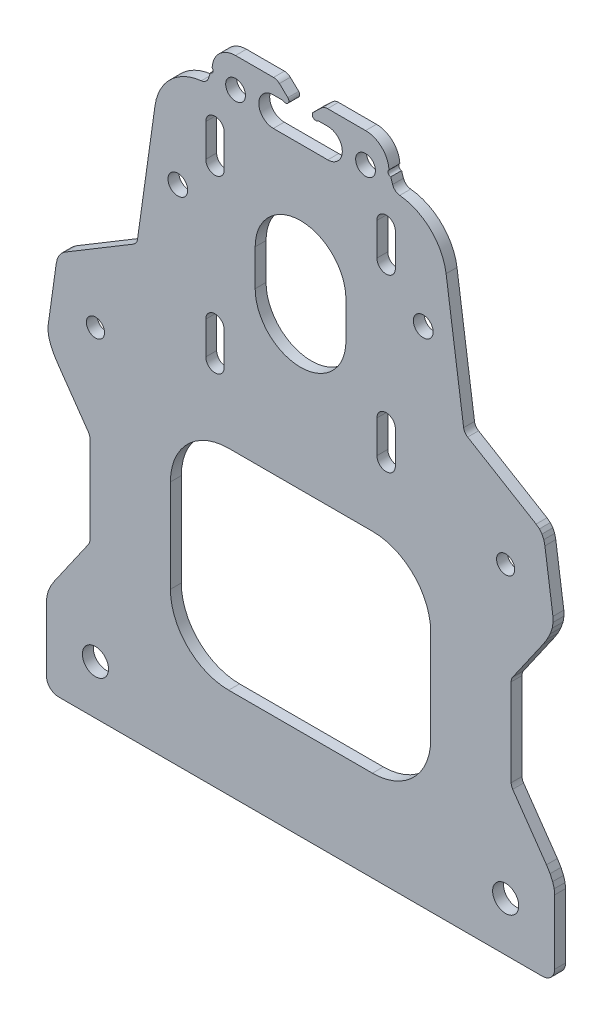
from build123d import *

# Parameters (mm, degrees)
MODEL_R             = 3.6
MODEL_R_2           = 2.725
MODEL_R_3           = 2.5
BOSS_EXTRUDE1_DEPTH = 3


with BuildPart() as part:
    # Model → Boss-Extrude1 (new body)
    with BuildSketch(Plane.XY):
        with BuildLine():
            Line((-66.64035, 0), (66.64035, 0))
            ThreePointArc((66.64035, 0), (69.016228785, 0.984121215), (70.00035, 3.36))
            Line((70.00035, 3.36), (70.00035, 21.1105))
            Line((70.00035, 21.1105), (69.86629813, 22.498114684))
            Line((69.86629813, 22.498114684), (69.446311232, 23.988387428))
            Line((69.446311232, 23.988387428), (68.733529412, 25.548929055))
            Line((68.733529412, 25.548929055), (67.734761359, 27.16155254))
            Line((67.734761359, 27.16155254), (58.431673409, 40.525169242))
            ThreePointArc((58.431673409, 40.525169242), (58.118153534, 41.164216889), (58.01035, 41.867818343))
            Line((58.01035, 41.867818343), (58.01035, 65.939651469))
            ThreePointArc((58.01035, 65.939651469), (58.11831888, 66.643779624), (58.432304432, 67.283206562))
            Line((58.432304432, 67.283206562), (66.78383855, 79.267931576))
            Line((66.78383855, 79.267931576), (67.914068691, 81.051661321))
            Line((67.914068691, 81.051661321), (68.763177176, 82.764680123))
            Line((68.763177176, 82.764680123), (69.316681884, 84.394671222))
            Line((69.316681884, 84.394671222), (69.565395366, 85.915970428))
            Line((69.565395366, 85.915970428), (69.519060346, 87.308284697))
            Line((69.519060346, 87.308284697), (67.30949192, 103.030180971))
            Line((67.30949192, 103.030180971), (66.999561947, 104.350057085))
            Line((66.999561947, 104.350057085), (66.487504991, 105.437863083))
            Line((66.487504991, 105.437863083), (65.782163484, 106.319853558))
            Line((65.782163484, 106.319853558), (64.875433482, 107.017560512))
            Line((64.875433482, 107.017560512), (46.0351373, 118.337952538))
            ThreePointArc((46.0351373, 118.337952538), (45.285845094, 119.055243779), (44.918346815, 120.025238907))
            Line((44.918346815, 120.025238907), (40.094015429, 154.352140382))
            ThreePointArc((40.094015429, 154.352140382), (35.836168672, 162.70125074), (27.337884769, 166.652968529))
            ThreePointArc((27.337884769, 166.652968529), (26.108825382, 167.158066229), (25.350203438, 168.24903067))
            Line((25.350203438, 168.24903067), (24.828755998, 169.817409171))
            ThreePointArc((24.828755998, 169.817409171), (24.117671094, 170.371357056), (24.355513409, 171.2408))
            ThreePointArc((24.355513409, 171.2408), (22.368316822, 175.612570409), (17.911140334, 177.4))
            Line((17.911140334, 177.4), (7.437786988, 177.4))
            ThreePointArc((7.437786988, 177.4), (6.567071518, 177.232740152), (5.820301357, 176.754769847))
            Line((5.820301357, 176.754769847), (3.50035, 174.5536))
            ThreePointArc((3.50035, 174.5536), (3.500375, 173.207275), (4.8467, 173.2073))
            Line((4.8467, 173.2073), (7.50035, 173.2073))
            ThreePointArc((7.50035, 173.2073), (11.50035, 169.2073), (7.50035, 165.2073))
            Line((7.50035, 165.2073), (-7.49965, 165.2073))
            ThreePointArc((-7.49965, 165.2073), (-11.49965, 169.2073), (-7.49965, 173.2073))
            Line((-7.49965, 173.2073), (-4.846, 173.2073))
            ThreePointArc((-4.846, 173.2073), (-3.499675, 173.207275), (-3.49965, 174.5536))
            Line((-3.49965, 174.5536), (-5.819601357, 176.754769848))
            ThreePointArc((-5.819601357, 176.754769848), (-6.566371518, 177.232740152), (-7.437086988, 177.4))
            Line((-7.437086988, 177.4), (-17.910440334, 177.4))
            ThreePointArc((-17.910440334, 177.4), (-22.367616822, 175.612570409), (-24.354813409, 171.2408))
            ThreePointArc((-24.354813409, 171.2408), (-24.116971094, 170.371357056), (-24.828055998, 169.817409171))
            Line((-24.828055998, 169.817409171), (-25.349503438, 168.24903067))
            ThreePointArc((-25.349503438, 168.24903067), (-26.108125382, 167.158066229), (-27.337184769, 166.652968529))
            ThreePointArc((-27.337184769, 166.652968529), (-35.835468672, 162.70125074), (-40.093315429, 154.352140382))
            Line((-40.093315429, 154.352140382), (-44.917646815, 120.025238907))
            ThreePointArc((-44.917646815, 120.025238907), (-45.285145095, 119.055243779), (-46.0344373, 118.337952538))
            Line((-46.0344373, 118.337952538), (-64.874733482, 107.017560512))
            Line((-64.874733482, 107.017560512), (-65.764454542, 106.336263813))
            Line((-65.764454542, 106.336263813), (-66.464064741, 105.473352073))
            Line((-66.464064741, 105.473352073), (-66.989930499, 104.37360872))
            Line((-66.989930499, 104.37360872), (-67.307930284, 103.030180971))
            Line((-67.307930284, 103.030180971), (-69.517498709, 87.308284697))
            Line((-69.517498709, 87.308284697), (-69.564336548, 85.915534746))
            Line((-69.564336548, 85.915534746), (-69.316250952, 84.392453689))
            Line((-69.316250952, 84.392453689), (-68.763104771, 82.761395172))
            Line((-68.763104771, 82.761395172), (-67.914669475, 81.049208688))
            Line((-67.914669475, 81.049208688), (-66.785659136, 79.267931576))
            Line((-66.785659136, 79.267931576), (-58.427548106, 67.280305558))
            ThreePointArc((-58.427548106, 67.280305558), (-58.113308938, 66.640672262), (-58.00525, 65.936257417))
            Line((-58.00525, 65.936257417), (-58.00525, 41.865084223))
            ThreePointArc((-58.00525, 41.865084223), (-58.113143434, 41.161196344), (-58.426916507, 40.521942406))
            Line((-58.426916507, 40.521942406), (-67.732826699, 27.16155254))
            Line((-67.732826699, 27.16155254), (-68.732119035, 25.548966105))
            Line((-68.732119035, 25.548966105), (-69.445294681, 23.988426858))
            Line((-69.445294681, 23.988426858), (-69.86552208, 22.498130488))
            Line((-69.86552208, 22.498130488), (-69.99965, 21.1105))
            Line((-69.99965, 21.1105), (-69.99965, 3.3593))
            ThreePointArc((-69.99965, 3.3593), (-69.01573381, 0.98391619), (-66.64035, 0))
        make_face()
        with Locations((-56.49965, 13.52)):
            Circle(MODEL_R, mode=Mode.SUBTRACT)
        with Locations((-17.89965, 169.2073)):
            Circle(MODEL_R_2, mode=Mode.SUBTRACT)
        with Locations((-33.79965, 138.65)):
            Circle(MODEL_R_2, mode=Mode.SUBTRACT)
        with Locations((-56.49965, 93.22)):
            Circle(MODEL_R_3, mode=Mode.SUBTRACT)
        with Locations((56.50035, 13.52)):
            Circle(MODEL_R, mode=Mode.SUBTRACT)
        with Locations((17.90035, 169.2073)):
            Circle(MODEL_R_2, mode=Mode.SUBTRACT)
        with Locations((33.80035, 138.65)):
            Circle(MODEL_R_2, mode=Mode.SUBTRACT)
        with Locations((56.50035, 93.22)):
            Circle(MODEL_R_3, mode=Mode.SUBTRACT)
        with BuildLine():
            Line((-19.80285, 25.0481), (19.80355, 25.0481))
            ThreePointArc((19.80355, 25.0481), (31.150351096, 29.748098904), (35.85035, 41.0949))
            Line((35.85035, 41.0949), (35.85035, 66.7013))
            ThreePointArc((35.85035, 66.7013), (31.150351096, 78.048101096), (19.80355, 82.7481))
            Line((19.80355, 82.7481), (-19.80285, 82.7481))
            ThreePointArc((-19.80285, 82.7481), (-31.149651096, 78.048101096), (-35.84965, 66.7013))
            Line((-35.84965, 66.7013), (-35.84965, 41.0949))
            ThreePointArc((-35.84965, 41.0949), (-31.149651096, 29.748098904), (-19.80285, 25.0481))
        make_face(mode=Mode.SUBTRACT)
        with BuildLine():
            Line((-26.10965, 157.54), (-26.10965, 148.54))
            ThreePointArc((-26.10965, 148.54), (-23.56965, 146), (-21.02965, 148.54))
            Line((-21.02965, 148.54), (-21.02965, 157.54))
            ThreePointArc((-21.02965, 157.54), (-23.56965, 160.08), (-26.10965, 157.54))
        make_face(mode=Mode.SUBTRACT)
        with BuildLine():
            Line((-26.10965, 110.4), (-26.10965, 101.4))
            ThreePointArc((-26.10965, 101.4), (-23.56965, 98.86), (-21.02965, 101.4))
            Line((-21.02965, 101.4), (-21.02965, 110.4))
            ThreePointArc((-21.02965, 110.4), (-23.56965, 112.94), (-26.10965, 110.4))
        make_face(mode=Mode.SUBTRACT)
        with BuildLine():
            Line((-12.49965, 134.47), (-12.49965, 124.47))
            ThreePointArc((-12.49965, 124.47), (0.00035, 111.97), (12.50035, 124.47))
            Line((12.50035, 124.47), (12.50035, 134.47))
            ThreePointArc((12.50035, 134.47), (0.00035, 146.97), (-12.49965, 134.47))
        make_face(mode=Mode.SUBTRACT)
        with BuildLine():
            Line((21.03035, 157.54), (21.03035, 148.54))
            ThreePointArc((21.03035, 148.54), (23.57035, 146), (26.11035, 148.54))
            Line((26.11035, 148.54), (26.11035, 157.54))
            ThreePointArc((26.11035, 157.54), (23.57035, 160.08), (21.03035, 157.54))
        make_face(mode=Mode.SUBTRACT)
        with BuildLine():
            Line((21.03035, 110.4), (21.03035, 101.4))
            ThreePointArc((21.03035, 101.4), (23.57035, 98.86), (26.11035, 101.4))
            Line((26.11035, 101.4), (26.11035, 110.4))
            ThreePointArc((26.11035, 110.4), (23.57035, 112.94), (21.03035, 110.4))
        make_face(mode=Mode.SUBTRACT)
    extrude(amount=BOSS_EXTRUDE1_DEPTH)


solid = part.part
